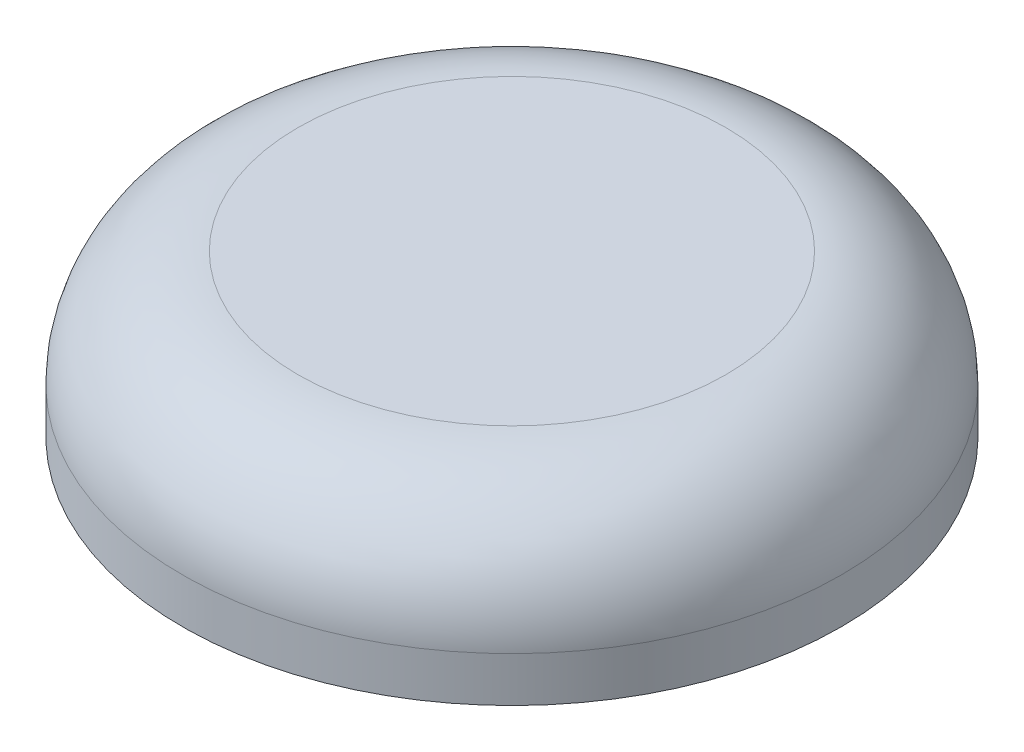
from build123d import *


with BuildPart() as part:
    # Sketch1 → Revolve1 (revolve)
    with BuildSketch(Plane.XY):
        with BuildLine():
            Line((-12.065, 0), (-12.065, -8.382))
            Line((-12.065, -8.382), (-19.558, -8.382))
            Line((-19.558, -8.382), (-19.558, -5.715))
            ThreePointArc((-19.558, -5.715), (-17.549338305, -0.865661695), (-12.7, 1.143))
            Line((-12.7, 1.143), (0, 1.143))
            Line((0, 1.143), (0, 0))
            Line((0, 0), (-12.065, 0))
        make_face()
    revolve(axis=Axis((0, 0, 0), (0, 1, 0)))


solid = part.part
